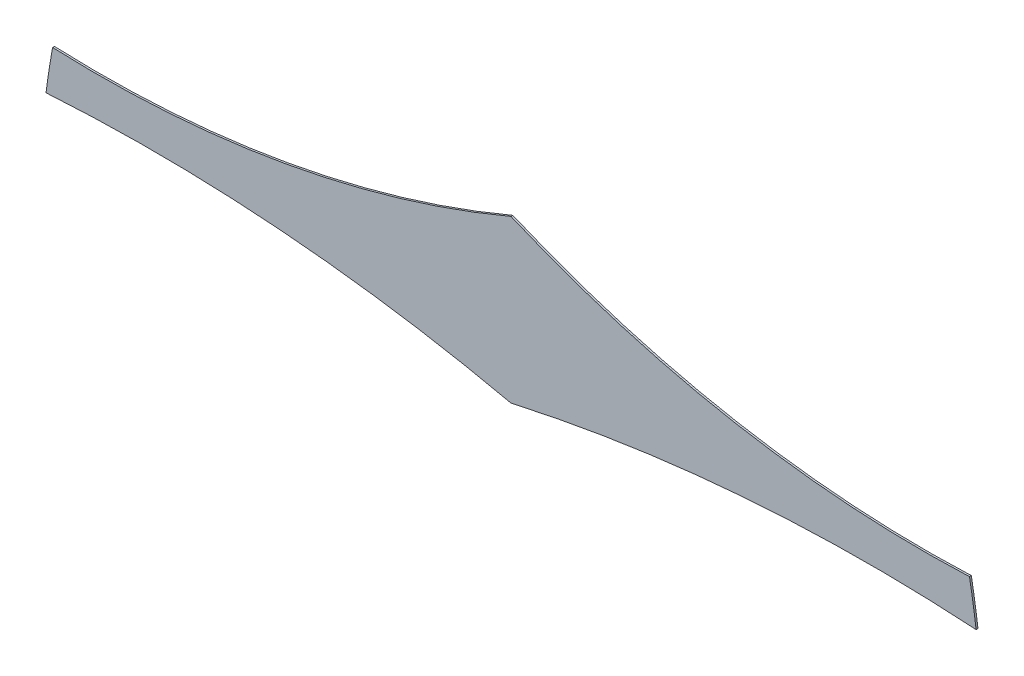
from build123d import *

# Parameters (mm, degrees)
SALIENTE_EXTRUIR1_DEPTH = 0.1


with BuildPart() as part:
    # Model → Saliente-Extruir1 (new body)
    with BuildSketch(Plane.XY):
        with BuildLine():
            ThreePointArc((35.800210803, 26.908728098), (48.149101643, 28.762497552), (60.636042467, 28.851238792))
            ThreePointArc((60.636042467, 28.851238792), (60.472080257, 29.990049682), (60.279817754, 31.124425713))
            ThreePointArc((60.279817754, 31.124425713), (47.792937284, 31.96838449), (35.798050693, 35.540099203))
            ThreePointArc((35.798050693, 35.540099203), (23.806490861, 31.964442335), (11.321987865, 31.115905838))
            ThreePointArc((11.321987865, 31.115905838), (11.131844141, 29.981551301), (10.96999091, 28.842815869))
            ThreePointArc((10.96999091, 28.842815869), (23.453817048, 28.757964702), (35.800210803, 26.908728098))
        make_face()
    extrude(amount=SALIENTE_EXTRUIR1_DEPTH)


solid = part.part
